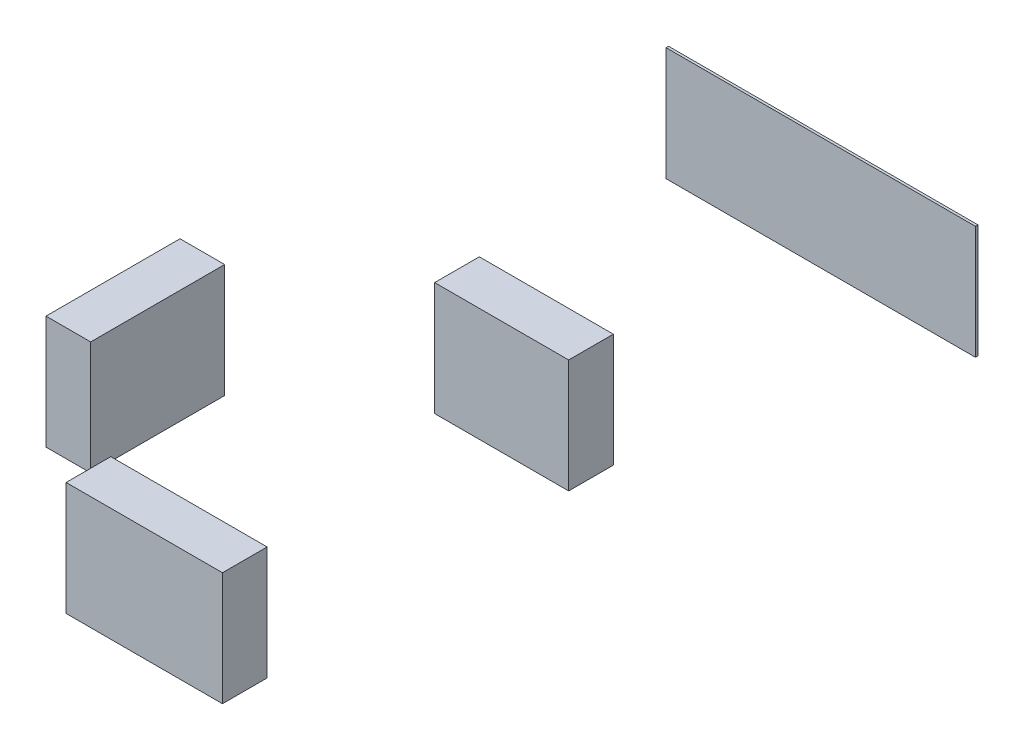
from build123d import *

# Parameters (mm, degrees)
SKETCH1_W             = 3.5
SKETCH1_H             = 1
BOSS_EXTRUDE1_DEPTH   = 2.54
SKETCH1_W_2           = 1
SKETCH1_H_2           = 3
BOSS_EXTRUDE1_2_DEPTH = 2.54
SKETCH1_W_3           = 3
BOSS_EXTRUDE1_3_DEPTH = 2.54
SKETCH1_W_4           = 6.926419092
SKETCH1_H_3           = 0.055914878
BOSS_EXTRUDE1_4_DEPTH = 2.54


with BuildPart() as part:
    # Sketch1 → Boss-Extrude1 (new body)
    with BuildSketch(Plane(origin=(0, 0, 0), x_dir=(1, 0, 0), z_dir=(0, 1, 0))):
        with Locations((4.7, 0.5)):
            Rectangle(SKETCH1_W, SKETCH1_H)
    extrude(amount=BOSS_EXTRUDE1_DEPTH)


with BuildPart() as body_2:
    # Sketch1 → Boss-Extrude1 2 (new body)
    with BuildSketch(Plane(origin=(0, 0, 0), x_dir=(1, 0, 0), z_dir=(0, 1, 0))):
        with Locations((0, 4.5)):
            Rectangle(SKETCH1_W_2, SKETCH1_H_2)
    extrude(amount=BOSS_EXTRUDE1_2_DEPTH)


with BuildPart() as body_3:
    # Sketch1 → Boss-Extrude1 3 (new body)
    with BuildSketch(Plane(origin=(0, 0, 0), x_dir=(1, 0, 0), z_dir=(0, 1, 0))):
        with Locations((4.7, 8.5)):
            Rectangle(SKETCH1_W_3, SKETCH1_H)
    extrude(amount=BOSS_EXTRUDE1_3_DEPTH)


with BuildPart() as body_4:
    # Sketch1 → Boss-Extrude1 4 (new body)
    with BuildSketch(Plane(origin=(0, 0, 0), x_dir=(1, 0, 0), z_dir=(0, 1, 0))):
        with Locations((4.7, 15.172042561)):
            Rectangle(SKETCH1_W_4, SKETCH1_H_3)
    extrude(amount=BOSS_EXTRUDE1_4_DEPTH)


solid = Compound([part.part, body_2.part, body_3.part, body_4.part])
